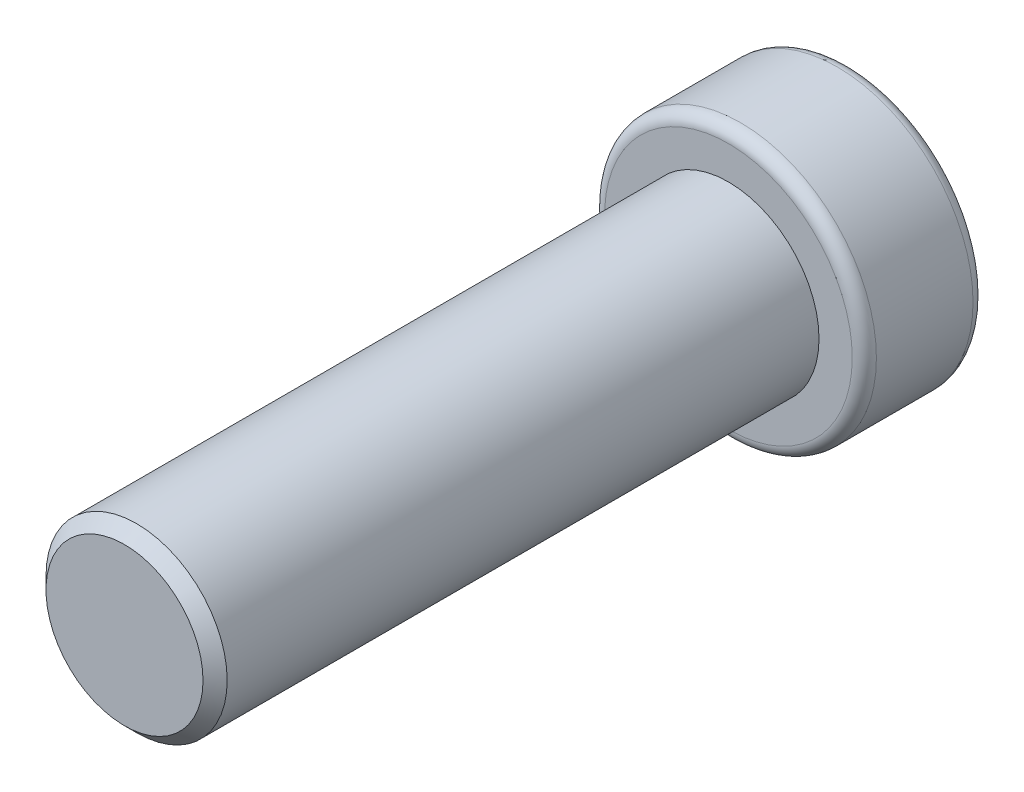
from build123d import *

# Parameters (mm, degrees)
CUT_EXTRUDE1_DEPTH = 1.5
CHAMFER1_SIZE      = 0.2


with BuildPart() as part:
    # Sketch1 → Revolve1 (revolve)
    with BuildSketch(Plane(origin=(0, 0, 0), x_dir=(1, 0, 0), z_dir=(0, 1, 0))):
        with BuildLine():
            Line((0, 12), (2.05, 12))
            ThreePointArc((2.05, 12), (2.191421356, 11.941421356), (2.25, 11.8))
            Line((2.25, 11.8), (2.25, 10.2))
            ThreePointArc((2.25, 10.2), (2.191421356, 10.058578644), (2.05, 10))
            Line((2.05, 10), (1.5, 10))
            Line((1.5, 10), (1.5, 0.2))
            Line((1.5, 0.2), (1.3, 0))
            Line((1.3, 0), (0, 0))
            Line((0, 0), (0, 12))
        make_face()
    revolve(axis=Axis((0, 0, 0), (0, 0, -1)))

    # Sketch2 → Cut-Extrude1 (cut)
    with BuildSketch(Plane(origin=(0, 0, -12), x_dir=(-1, 0, 0), z_dir=(0, 0, -1))):
        Polygon((1.25, 0.721687836), (0, 1.443375673), (-1.25, 0.721687836), (-1.25, -0.721687836), (0, -1.443375673), (1.25, -0.721687836), align=None)
    extrude(amount=-CUT_EXTRUDE1_DEPTH, mode=Mode.SUBTRACT)

    # Chamfer1
    chamfer1_edges = [part.edges().sort_by_distance(p)[0] for p in [
        (-1.25, 0, -10.5),
        (-0.625, -1.082531755, -10.5),
        (0.625, -1.082531755, -10.5),
        (1.25, 0, -10.5),
        (0.625, 1.082531755, -10.5),
        (-0.625, 1.082531755, -10.5),
    ]]
    chamfer(chamfer1_edges, length=CHAMFER1_SIZE)


solid = part.part
